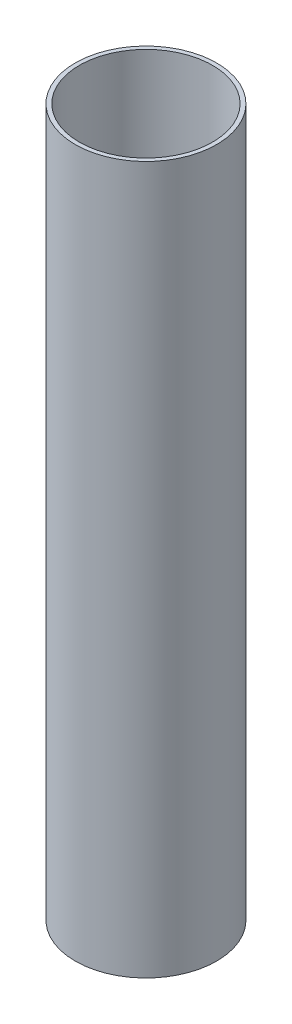
from build123d import *

# Parameters (mm, degrees)
SKETCH1_R   = 6.35
SKETCH1_R_2 = 5.98048883


with BuildPart() as part:
    # Sweep1: sweep along a path in Sketch2
    with BuildLine(Plane(origin=(0, 0, 0), x_dir=(0, 0, -1), z_dir=(1, 0, 0))) as sweep1_path:
        Line((0, 0), (0, 63.5))
    # Sketch1 → Sweep1 (sweep)
    with BuildSketch(Plane(origin=(0, 0, 0), x_dir=(1, 0, 0), z_dir=(0, 1, 0))):
        Circle(SKETCH1_R)
        Circle(SKETCH1_R_2, mode=Mode.SUBTRACT)
    sweep(path=sweep1_path.line)


solid = part.part
